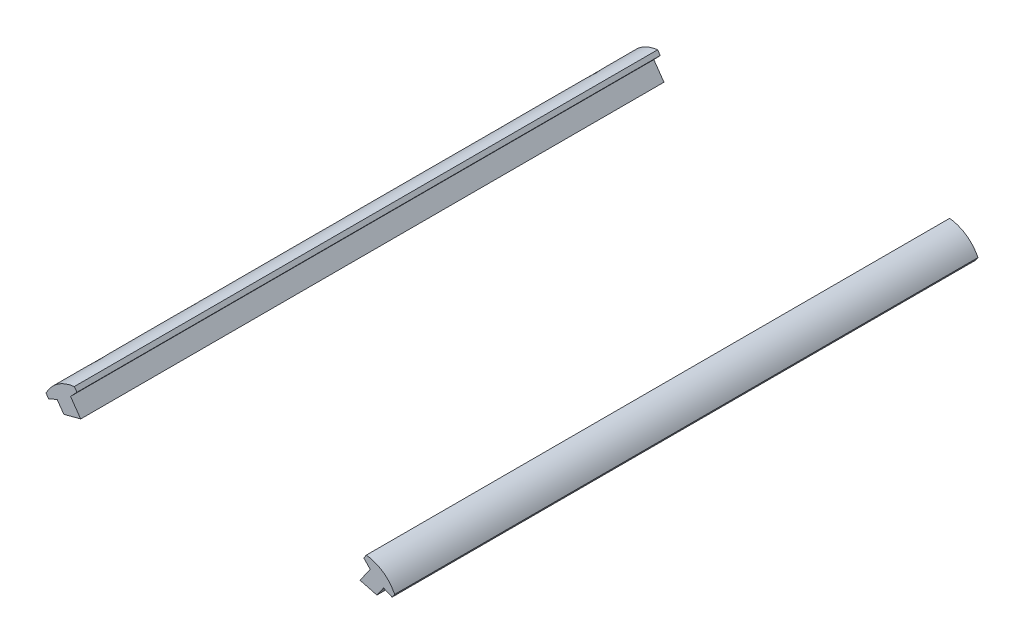
from build123d import *

# Parameters (mm, degrees)
BOSS_EXTRUDE1_DEPTH   = 152.4
BOSS_EXTRUDE1_2_DEPTH = 152.4


with BuildPart() as part:
    # Sketch1 → Boss-Extrude1 (new body)
    with BuildSketch(Plane.XY):
        with BuildLine():
            Line((-36.49122578, 147.966720721), (-39.142437036, 151.753843735))
            Line((-39.142437036, 151.753843735), (-37.467637136, 153.526320702))
            Line((-37.467637136, 153.526320702), (-38.144971739, 154.493859392))
            add(Edge.make_bspline(
                [(-45.552343011, 149.308259131), (-43.180649259, 153.803743217), (-38.144971739, 154.493859392)],
                knots=[0, 0, 0, 1, 1, 1], degree=2))
            Line((-45.552343011, 149.308259131), (-44.875008407, 148.34072044))
            Line((-44.875008407, 148.34072044), (-42.636417316, 149.30784982))
            Line((-42.636417316, 149.30784982), (-40.889317917, 146.812205488))
            ThreePointArc((-40.889317917, 146.812205488), (-38.694577942, 147.40586704), (-36.49122578, 147.966720721))
        make_face()
    extrude(amount=BOSS_EXTRUDE1_DEPTH)


with BuildPart() as body_2:
    # Sketch1 → Boss-Extrude1 2 (new body)
    with BuildSketch(Plane.XY):
        with BuildLine():
            Line((36.49122578, 147.966720721), (39.142437036, 151.753843735))
            Line((39.142437036, 151.753843735), (37.467637136, 153.526320702))
            Line((37.467637136, 153.526320702), (38.144971739, 154.493859392))
            add(Edge.make_bspline(
                [(45.552343011, 149.308259131), (43.180649259, 153.803743217), (38.144971739, 154.493859392)],
                knots=[0, 0, 0, 1, 1, 1], degree=2))
            Line((45.552343011, 149.308259131), (44.875008407, 148.34072044))
            Line((44.875008407, 148.34072044), (42.636417316, 149.30784982))
            Line((42.636417316, 149.30784982), (40.889317917, 146.812205488))
            ThreePointArc((40.889317917, 146.812205488), (38.694577942, 147.40586704), (36.49122578, 147.966720721))
        make_face()
    extrude(amount=BOSS_EXTRUDE1_2_DEPTH)


solid = Compound([part.part, body_2.part])
